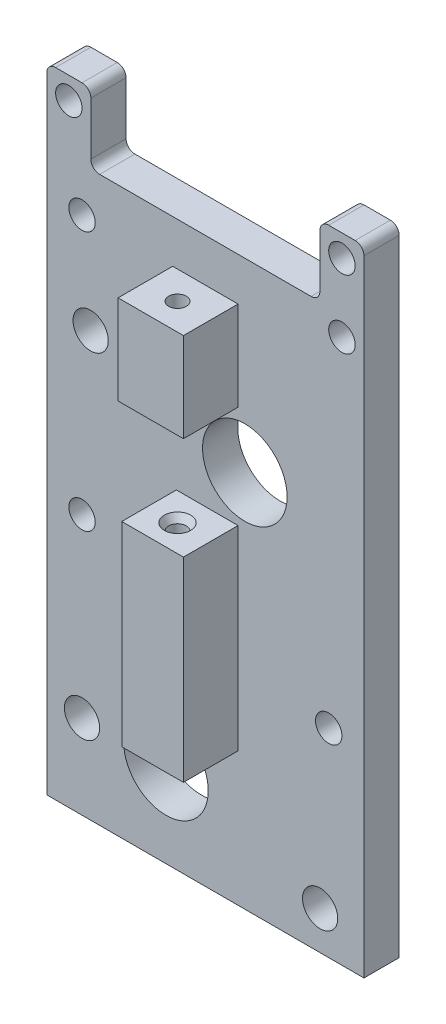
from build123d import *

# Parameters (mm, degrees)
BOSS_EXTRUDE1_DEPTH = 4
SKETCH2_R           = 1.5
SKETCH2_R_2         = 4.8
SKETCH2_R_3         = 2
CUT_EXTRUDE1_DEPTH  = 10
SKETCH3_W           = 7
SKETCH3_H           = 22.146248503
SKETCH3_W_2         = 7.418721668
SKETCH3_H_2         = 10.140288501
BOSS_EXTRUDE2_DEPTH = 6.2
SKETCH4_R           = 1
CUT_EXTRUDE2_DEPTH  = 70
SKETCH5_R           = 1.5
CUT_EXTRUDE3_DEPTH  = 3
CUT_EXTRUDE3_DRAFT  = -32


with BuildPart() as part:
    # Sketch1 → Boss-Extrude1 (new body)
    with BuildSketch(Plane.XY):
        with BuildLine():
            Line((18, 32), (18, 39))
            ThreePointArc((18, 39), (17.707106781, 39.707106781), (17, 40))
            Line((17, 40), (14, 40))
            ThreePointArc((14, 40), (13.292893219, 39.707106781), (13, 39))
            Line((13, 39), (13, 33))
            ThreePointArc((13, 33), (12.707106781, 32.292893219), (12, 32))
            Line((12, 32), (-12, 32))
            ThreePointArc((-12, 32), (-12.707106781, 32.292893219), (-13, 33))
            Line((-13, 33), (-13, 39))
            ThreePointArc((-13, 39), (-13.292893219, 39.707106781), (-14, 40))
            Line((-14, 40), (-17, 40))
            ThreePointArc((-17, 40), (-17.707106781, 39.707106781), (-18, 39))
            Line((-18, 39), (-18, 32))
            Line((-18, 32), (-18, -32))
            Line((-18, -32), (18, -32))
            Line((18, -32), (18, 32))
        make_face()
    extrude(amount=BOSS_EXTRUDE1_DEPTH)

    # Sketch2 → Cut-Extrude1 (cut)
    with BuildSketch(Plane.XY.offset(4)):
        with Locations((15.5, 29.744145571)):
            Circle(SKETCH2_R)
        with Locations((-14, 27)):
            Circle(SKETCH2_R)
        with Locations((4.475, 10.927702889)):
            Circle(SKETCH2_R_2)
        with Locations((-14, -2.442942894)):
            Circle(SKETCH2_R)
        with Locations((14, -9.442942894)):
            Circle(SKETCH2_R)
        with Locations((-4.475, -22.442942894)):
            Circle(SKETCH2_R_2)
        with Locations((13.025, -27.642942894)):
            Circle(SKETCH2_R_3)
        with Locations((-14, -22.442942894)):
            Circle(SKETCH2_R_3)
        with Locations((-13.025, 16.127702889)):
            Circle(SKETCH2_R_3)
        with Locations((15.5, 37.5)):
            Circle(SKETCH2_R)
        with Locations((-15.5, 37.5)):
            Circle(SKETCH2_R)
    extrude(amount=-CUT_EXTRUDE1_DEPTH, mode=Mode.SUBTRACT)

    # Sketch3 → Boss-Extrude2 (add)
    with BuildSketch(Plane.XY.offset(4)):
        with Locations((0.209360834, -5.740885149)):
            Rectangle(SKETCH3_W, SKETCH3_H)
        with Locations((0, 22.037818849)):
            Rectangle(SKETCH3_W_2, SKETCH3_H_2)
    extrude(amount=BOSS_EXTRUDE2_DEPTH)

    # Sketch4 → Cut-Extrude2 (cut)
    with BuildSketch(Plane.XZ.offset(16.8140094)):
        with Locations((0, 7.165)):
            Circle(SKETCH4_R)
    extrude(amount=-CUT_EXTRUDE2_DEPTH, mode=Mode.SUBTRACT)


with BuildPart() as cut_extrude3_tool:
    # Sketch5 → Cut-Extrude3 (with draft: the straight prism first)
    with BuildSketch(Plane(origin=(0, 5.332239103, 0), x_dir=(-1, 0, 0), z_dir=(0, 1, 0))):
        with Locations((0, 7.165)):
            Circle(SKETCH5_R)
    extrude(amount=-CUT_EXTRUDE3_DEPTH)
    # Cut-Extrude3: the draft: its side faces are tilted about the plane it starts from
    cut_extrude3_sides = [cut_extrude3_tool.faces().sort_by_distance(p)[0] for p in [
        (1.5, 3.832239103, 7.165),
    ]]
    draft(cut_extrude3_sides, Plane(origin=(0, 5.332239103, 0), x_dir=(-1, 0, 0), z_dir=(0, 1, 0)), CUT_EXTRUDE3_DRAFT)


with BuildPart() as part_1:
    add(part.part)

    # Cut-Extrude3: cut by cut_extrude3_tool
    add(cut_extrude3_tool.part, mode=Mode.SUBTRACT)


solid = part_1.part
